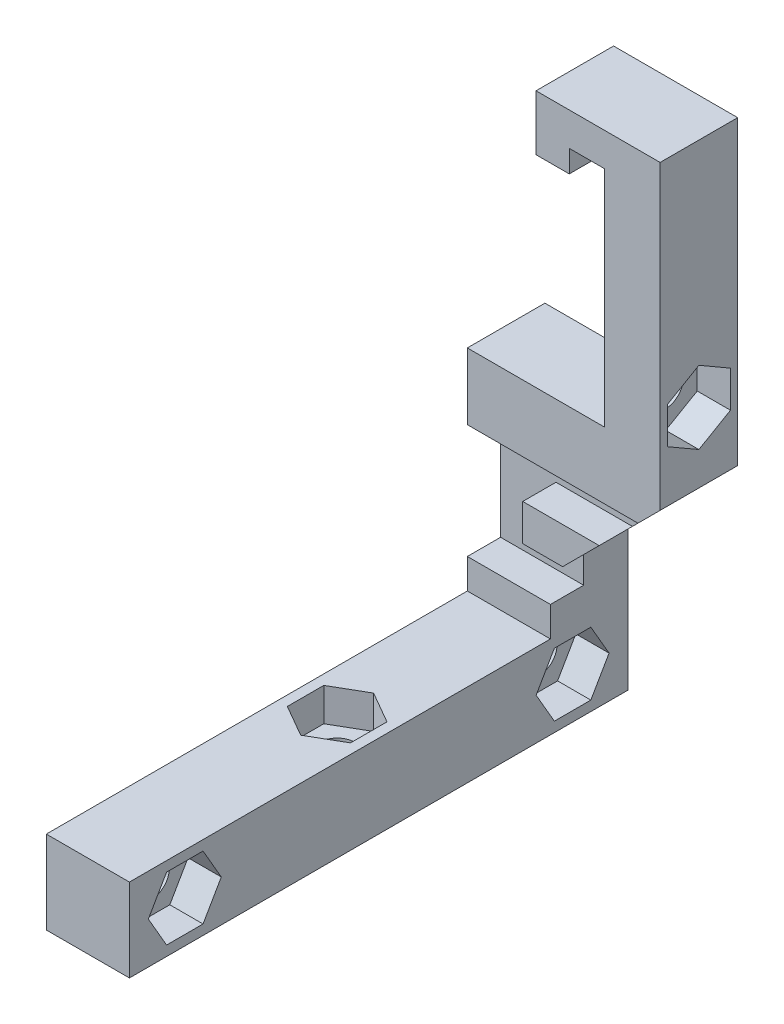
from build123d import *

# Parameters (mm, degrees)
SALIENTE_EXTRUIR1_DEPTH = 4
SALIENTE_EXTRUIR2_DEPTH = 3
CROQUIS3_W              = 7.5
CROQUIS3_H              = 7.5
SALIENTE_EXTRUIR3_DEPTH = 38
CORTAR_EXTRUIR1_REACH   = 7
CROQUIS4_R              = 1.6
CORTAR_EXTRUIR2_DEPTH   = 3
CORTAR_EXTRUIR3_REACH   = 19.4
CROQUIS6_R              = 1.6
CORTAR_EXTRUIR4_DEPTH   = 3
CORTAR_EXTRUIR5_REACH   = 51.7
CROQUIS8_R              = 1.6
CORTAR_EXTRUIR6_DEPTH   = 3
CORTAR_EXTRUIR7_REACH   = 14.4
CROQUIS10_W             = 3
CROQUIS10_H             = 3.5


with BuildPart() as part:
    # Croquis1 → Saliente-Extruir1 (new body)
    with BuildSketch(Plane.XY):
        Polygon((0, 26.5), (0, 0), (7.5, 0), (7.5, 12.6), (17.4, 22.5), (17.4, 49.7), (6.2, 49.7), (6.2, 44.7), (9.2, 44.7), (9.2, 46.7), (12.4, 46.7), (12.4, 26.5), align=None)
    extrude(amount=SALIENTE_EXTRUIR1_DEPTH)

    # Croquis2 → Saliente-Extruir2 (add)
    with BuildSketch(Plane.XY.offset(4)):
        Polygon((0, 0), (0, 10.2), (5, 10.2), (5, 20.5), (0, 20.5), (0, 26.5), (12.4, 26.5), (12.4, 46.7), (9.2, 46.7), (9.2, 44.7), (6.2, 44.7), (6.2, 49.7), (17.4, 49.7), (17.4, 22.5), (7.5, 12.6), (7.5, 0), align=None)
    extrude(amount=SALIENTE_EXTRUIR2_DEPTH)

    # Croquis3 → Saliente-Extruir3 (add)
    with BuildSketch(Plane.XY.offset(7)):
        with Locations((3.75, 3.75)):
            Rectangle(CROQUIS3_W, CROQUIS3_H)
    extrude(amount=SALIENTE_EXTRUIR3_DEPTH)

    # Croquis4 → Cortar-Extruir1 (cut, up to next)
    with BuildSketch(Plane.ZY.offset(-12.4), mode=Mode.PRIVATE) as cortar_extruir1_sk1:
        with Locations((3.5, 28.8)):
            Circle(CROQUIS4_R)
    cortar_extruir1_tool1 = extrude(cortar_extruir1_sk1.sketch, amount=-CORTAR_EXTRUIR1_REACH, mode=Mode.PRIVATE) & part.part
    add(cortar_extruir1_tool1.solids().sort_by_distance((12.4, 28.8, 3.5))[0], mode=Mode.SUBTRACT)

    # Croquis5 → Cortar-Extruir2 (cut)
    with BuildSketch(Plane(origin=(17.4, 0, 0), x_dir=(0, 0, -1), z_dir=(1, 0, 0))):
        Polygon((-0.65, 30.445448267), (-3.5, 32.090896534), (-6.35, 30.445448267), (-6.35, 27.154551733), (-3.5, 25.509103466), (-0.65, 27.154551733), align=None)
    extrude(amount=-CORTAR_EXTRUIR2_DEPTH, mode=Mode.SUBTRACT)

    # Croquis6 → Cortar-Extruir3 (cut, up to next)
    with BuildSketch(Plane.ZY, mode=Mode.PRIVATE) as cortar_extruir3_sk1:
        with Locations((5, 3.75)):
            Circle(CROQUIS6_R)
    cortar_extruir3_tool1 = extrude(cortar_extruir3_sk1.sketch, amount=-CORTAR_EXTRUIR3_REACH, mode=Mode.PRIVATE) & part.part
    add(cortar_extruir3_tool1.solids().sort_by_distance((0, 3.75, 5))[0], mode=Mode.SUBTRACT)
    # Croquis6 → Cortar-Extruir3 (cut, up to next)
    with BuildSketch(Plane.ZY, mode=Mode.PRIVATE) as cortar_extruir3_sk2:
        with Locations((40, 3.75)):
            Circle(CROQUIS6_R)
    cortar_extruir3_tool2 = extrude(cortar_extruir3_sk2.sketch, amount=-CORTAR_EXTRUIR3_REACH, mode=Mode.PRIVATE) & part.part
    add(cortar_extruir3_tool2.solids().sort_by_distance((0, 3.75, 40))[0], mode=Mode.SUBTRACT)

    # Croquis7 → Cortar-Extruir4 (cut)
    with BuildSketch(Plane(origin=(7.5, 0, 0), x_dir=(0, 0, -1), z_dir=(1, 0, 0))):
        Polygon((-3.354551733, 6.6), (-6.645448267, 6.6), (-8.290896534, 3.75), (-6.645448267, 0.9), (-3.354551733, 0.9), (-1.709103466, 3.75), align=None)
        Polygon((-38.354551733, 6.6), (-41.645448267, 6.6), (-43.290896534, 3.75), (-41.645448267, 0.9), (-38.354551733, 0.9), (-36.709103466, 3.75), align=None)
    extrude(amount=-CORTAR_EXTRUIR4_DEPTH, mode=Mode.SUBTRACT)

    # Croquis8 → Cortar-Extruir5 (cut, up to next)
    with BuildSketch(Plane.XZ, mode=Mode.PRIVATE) as cortar_extruir5_sk1:
        with Locations((3.75, 22.5)):
            Circle(CROQUIS8_R)
    cortar_extruir5_tool1 = extrude(cortar_extruir5_sk1.sketch, amount=-CORTAR_EXTRUIR5_REACH, mode=Mode.PRIVATE) & part.part
    add(cortar_extruir5_tool1.solids().sort_by_distance((3.75, 0, 22.5))[0], mode=Mode.SUBTRACT)

    # Croquis9 → Cortar-Extruir6 (cut)
    with BuildSketch(Plane(origin=(0, 7.5, 0), x_dir=(1, 0, 0), z_dir=(0, 1, 0))):
        Polygon((0.9, -20.854551733), (0.9, -24.145448267), (3.75, -25.790896534), (6.6, -24.145448267), (6.6, -20.854551733), (3.75, -19.209103466), align=None)
    extrude(amount=-CORTAR_EXTRUIR6_DEPTH, mode=Mode.SUBTRACT)

    # Croquis10 → Cortar-Extruir7 (cut, up to next)
    with BuildSketch(Plane.ZY.offset(-5), mode=Mode.PRIVATE) as cortar_extruir7_sk1:
        with Locations((5.5, 11.95)):
            Rectangle(CROQUIS10_W, CROQUIS10_H)
    cortar_extruir7_tool1 = extrude(cortar_extruir7_sk1.sketch, amount=-CORTAR_EXTRUIR7_REACH, mode=Mode.PRIVATE) & part.part
    add(cortar_extruir7_tool1.solids().sort_by_distance((5, 11.95, 5.5))[0], mode=Mode.SUBTRACT)
    # Croquis10 → Cortar-Extruir7 (cut, up to next)
    with BuildSketch(Plane.ZY.offset(-5), mode=Mode.PRIVATE) as cortar_extruir7_sk2:
        with Locations((5.5, 18.75)):
            Rectangle(CROQUIS10_W, CROQUIS10_H)
    cortar_extruir7_tool2 = extrude(cortar_extruir7_sk2.sketch, amount=-CORTAR_EXTRUIR7_REACH, mode=Mode.PRIVATE) & part.part
    add(cortar_extruir7_tool2.solids().sort_by_distance((5, 18.75, 5.5))[0], mode=Mode.SUBTRACT)


solid = part.part
